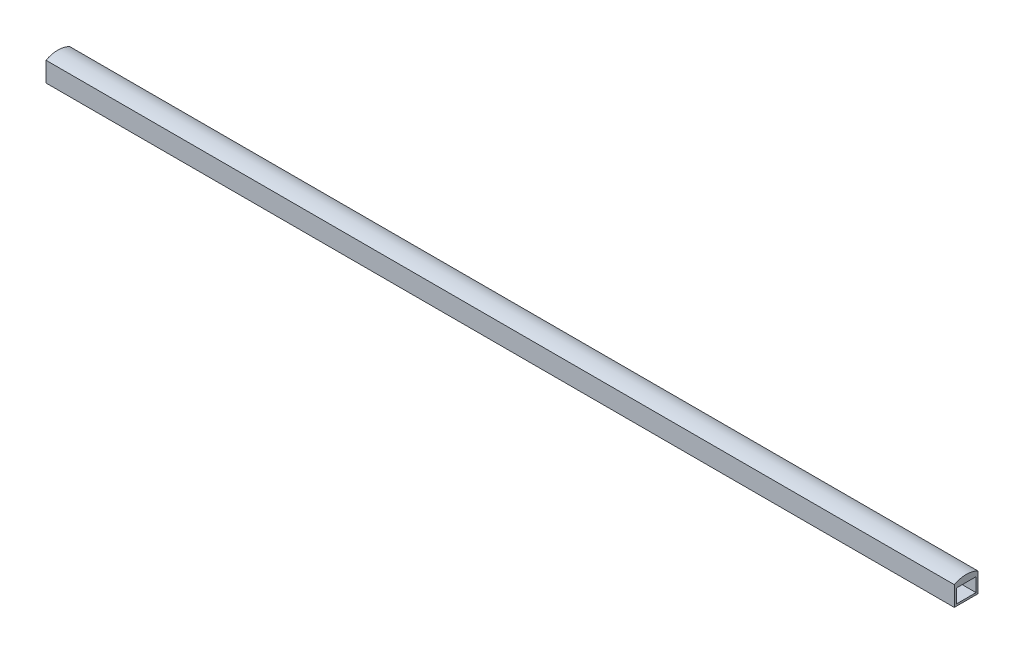
from build123d import *

# Parameters (mm, degrees)
CROQUIS1_W              = 460
CROQUIS1_H              = 12
SALIENTE_EXTRUIR1_DEPTH = 10
CROQUIS2_W              = 10
CROQUIS2_H              = 7
CORTAR_EXTRUIR1_DEPTH   = 970
SALIENTE_EXTRUIR2_DEPTH = 460


with BuildPart() as part:
    # Croquis1 → Saliente-Extruir1 (new body)
    with BuildSketch(Plane(origin=(0, 0, 0), x_dir=(1, 0, 0), z_dir=(0, 1, 0))):
        with Locations((230, 6)):
            Rectangle(CROQUIS1_W, CROQUIS1_H)
    extrude(amount=SALIENTE_EXTRUIR1_DEPTH)

    # Croquis2 → Cortar-Extruir1 (cut)
    with BuildSketch(Plane.ZY):
        with Locations((-6, 4.5)):
            Rectangle(CROQUIS2_W, CROQUIS2_H)
    extrude(amount=-CORTAR_EXTRUIR1_DEPTH, mode=Mode.SUBTRACT)

    # Croquis3 → Saliente-Extruir2 (add)
    with BuildSketch(Plane.ZY):
        with BuildLine():
            ThreePointArc((0, 10), (-6, 11.465101961), (-12, 10))
            Line((-12, 10), (0, 10))
        make_face()
    extrude(amount=-SALIENTE_EXTRUIR2_DEPTH)


solid = part.part
